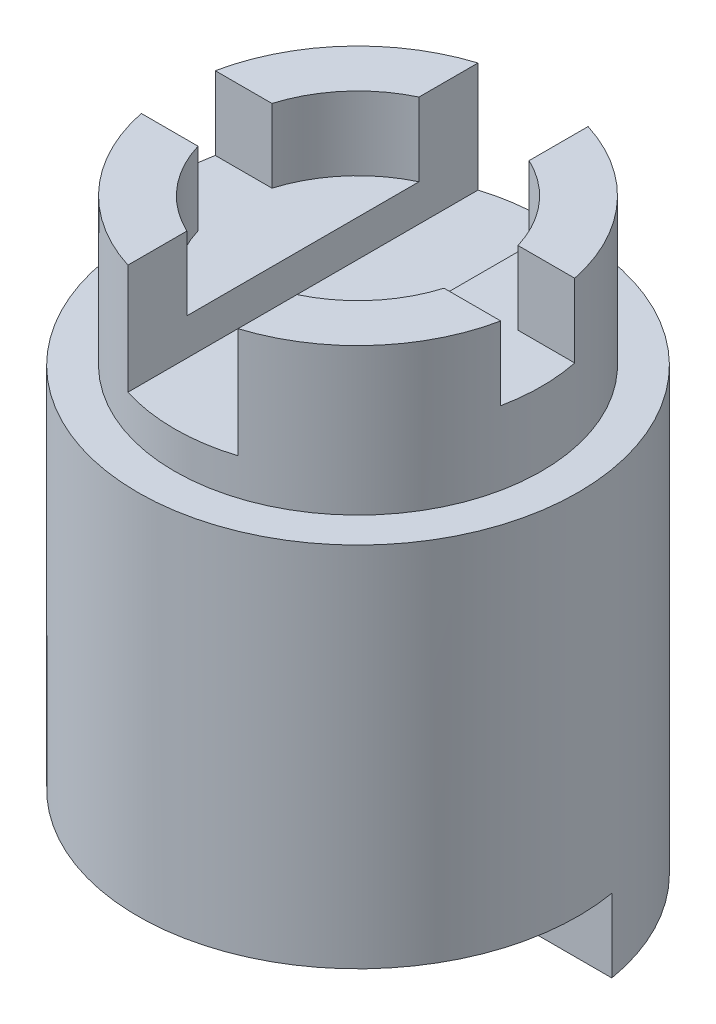
from build123d import *

# Parameters (mm, degrees)
SKETCH1_R                              = 19.05
F_1_5_DIAMETER_2_TALL_CYLINDER_DEPTH   = 50.8
SKETCH2_R                              = 19.05
SKETCH2_R_2                            = 15.875
F_1_25_DIAMETER_X_5_CYLINDER_CUT_DEPTH = 12.7
SKETCH3_R                              = 11.1125
CUT_EXTRUDE2_DEPTH                     = 6.35
SKETCH4_W                              = 9.525
SKETCH4_H                              = 38.1
CUT_EXTRUDE3_DEPTH                     = 9.525
SKETCH5_W                              = 38.1
SKETCH5_H                              = 6.4008
CUT_EXTRUDE4_DEPTH                     = 6.35
SKETCH11_R                             = 9.525
CUT_EXTRUDE5_DEPTH                     = 6.35
SKETCH12_W                             = 6.4008
SKETCH12_H                             = 19.05
CUT_EXTRUDE6_DEPTH                     = 6.35
SKETCH13_W                             = 38.1
SKETCH13_H                             = 22.225
CUT_EXTRUDE7_DEPTH                     = 6.35


with BuildPart() as part:
    # Sketch1 → 1.5" diameter 2" tall cylinder (new body)
    with BuildSketch(Plane(origin=(0, 0, 0), x_dir=(1, 0, 0), z_dir=(0, 1, 0))):
        Circle(SKETCH1_R)
    extrude(amount=F_1_5_DIAMETER_2_TALL_CYLINDER_DEPTH)

    # Sketch2 → 1.25" diameter x .5" cylinder cut (cut)
    with BuildSketch(Plane(origin=(0, 50.8, 0), x_dir=(1, 0, 0), z_dir=(0, 1, 0))):
        Circle(SKETCH2_R)
        Circle(SKETCH2_R_2, mode=Mode.SUBTRACT)
    extrude(amount=-F_1_25_DIAMETER_X_5_CYLINDER_CUT_DEPTH, mode=Mode.SUBTRACT)

    # Sketch3 → Cut-Extrude2 (cut)
    with BuildSketch(Plane(origin=(0, 50.8, 0), x_dir=(1, 0, 0), z_dir=(0, 1, 0))):
        Circle(SKETCH3_R)
    extrude(amount=-CUT_EXTRUDE2_DEPTH, mode=Mode.SUBTRACT)

    # Sketch4 → Cut-Extrude3 (cut)
    with BuildSketch(Plane(origin=(0, 50.8, 0), x_dir=(1, 0, 0), z_dir=(0, 1, 0))):
        Rectangle(SKETCH4_W, SKETCH4_H)
    extrude(amount=-CUT_EXTRUDE3_DEPTH, mode=Mode.SUBTRACT)

    # Sketch5 → Cut-Extrude4 (cut)
    with BuildSketch(Plane(origin=(0, 50.8, 0), x_dir=(1, 0, 0), z_dir=(0, 1, 0))):
        Rectangle(SKETCH5_W, SKETCH5_H)
    extrude(amount=-CUT_EXTRUDE4_DEPTH, mode=Mode.SUBTRACT)

    # Sketch11 → Cut-Extrude5 (cut)
    with BuildSketch(Plane(origin=(0, 0, 0), x_dir=(-1, 0, 0), z_dir=(0, -1, 0))):
        Circle(SKETCH11_R)
    extrude(amount=-CUT_EXTRUDE5_DEPTH, mode=Mode.SUBTRACT)

    # Sketch12 → Cut-Extrude6 (cut)
    with BuildSketch(Plane.XZ):
        with Locations((0, -9.525)):
            Rectangle(SKETCH12_W, SKETCH12_H)
    extrude(amount=-CUT_EXTRUDE6_DEPTH, mode=Mode.SUBTRACT)

    # Sketch13 → Cut-Extrude7 (cut)
    with BuildSketch(Plane.XZ):
        with Locations((0, 7.9375)):
            Rectangle(SKETCH13_W, SKETCH13_H)
    extrude(amount=-CUT_EXTRUDE7_DEPTH, mode=Mode.SUBTRACT)


solid = part.part
